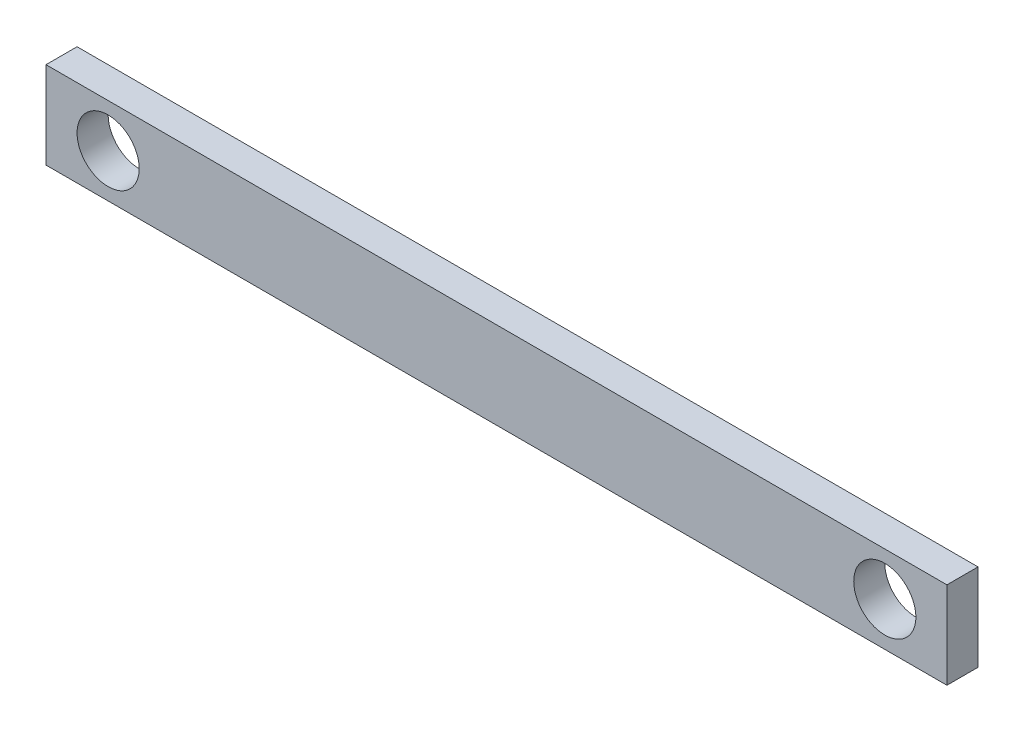
from build123d import *

# Parameters (mm, degrees)
SKETCH1_W           = 3930
SKETCH1_H           = 140
BOSS_EXTRUDE1_DEPTH = 50
SKETCH2_R           = 50
CUT_EXTRUDE1_DEPTH  = 50
SKETCH3_W           = 100
SKETCH3_H           = 140
BOSS_EXTRUDE2_DEPTH = 50
SKETCH4_R           = 50
CUT_EXTRUDE2_DEPTH  = 51
SKETCH5_W           = 1450
SKETCH5_H           = 140
SKETCH5_R           = 50
BOSS_EXTRUDE3_DEPTH = 50
SKETCH6_W           = 4130
SKETCH6_H           = 140
CUT_EXTRUDE3_DEPTH  = 50


with BuildPart() as part:
    # Sketch1 → Boss-Extrude1 (new body)
    with BuildSketch(Plane.XY):
        with Locations((1965, 70)):
            Rectangle(SKETCH1_W, SKETCH1_H)
    extrude(amount=BOSS_EXTRUDE1_DEPTH)

    # Sketch2 → Cut-Extrude1 (cut)
    with BuildSketch(Plane.XY.offset(50)):
        with Locations((3930, 70)):
            Circle(SKETCH2_R)
        with Locations((0, 70)):
            Circle(SKETCH2_R)
    extrude(amount=-CUT_EXTRUDE1_DEPTH, mode=Mode.SUBTRACT)

    # Sketch3 → Boss-Extrude2 (add, through all)
    with BuildSketch(Plane(origin=(0, 0, 0), x_dir=(-1, 0, 0), z_dir=(0, 0, -1))):
        with Locations((-3980, 70)):
            Rectangle(SKETCH3_W, SKETCH3_H)
        with Locations((50, 70)):
            Rectangle(SKETCH3_W, SKETCH3_H)
    extrude(amount=-BOSS_EXTRUDE2_DEPTH)

    # Sketch4 → Cut-Extrude2 (cut, through all)
    with BuildSketch(Plane(origin=(0, 0, 0), x_dir=(-1, 0, 0), z_dir=(0, 0, -1))):
        with Locations((0, 70)):
            Circle(SKETCH4_R)
        with Locations((-3930, 70)):
            Circle(SKETCH4_R)
    extrude(amount=-CUT_EXTRUDE2_DEPTH, mode=Mode.SUBTRACT)

    # Sketch6 → Cut-Extrude3 (cut)
    with BuildSketch(Plane.XY.offset(50)):
        with Locations((1965, 70)):
            Rectangle(SKETCH6_W, SKETCH6_H)
    extrude(amount=-CUT_EXTRUDE3_DEPTH, mode=Mode.SUBTRACT)


with BuildPart() as body_2:
    # Sketch5 → Boss-Extrude3 (new body)
    with BuildSketch(Plane(origin=(0, 0, -10), x_dir=(-1, 0, 0), z_dir=(0, 0, -1))):
        with Locations((-3305, 70)):
            Rectangle(SKETCH5_W, SKETCH5_H)
        with Locations((-3930, 70)):
            Circle(SKETCH5_R, mode=Mode.SUBTRACT)
        with Locations((-2680, 70)):
            Circle(SKETCH5_R, mode=Mode.SUBTRACT)
    extrude(amount=BOSS_EXTRUDE3_DEPTH)


solid = body_2.part
